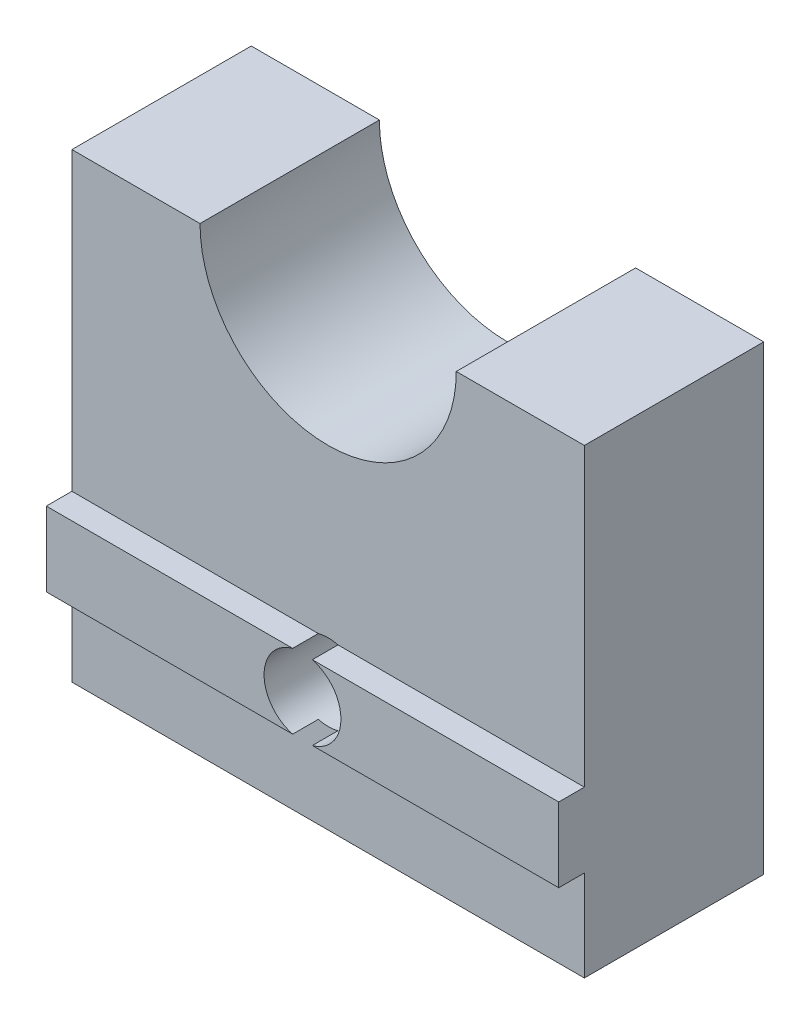
from build123d import *

# Parameters (mm, degrees)
BOSS_EXTRUDE1_DEPTH = 7
SKETCH2_W           = 1
SKETCH2_H           = 2.9
BOSS_EXTRUDE2_DEPTH = 20
SKETCH3_R           = 1.5
CUT_EXTRUDE1_DEPTH  = 9


with BuildPart() as part:
    # Sketch1 → Boss-Extrude1 (new body)
    with BuildSketch(Plane.XY):
        with BuildLine():
            Line((-10, 0), (10, 0))
            Line((10, 0), (10, 18))
            Line((10, 18), (5, 18))
            ThreePointArc((5, 18), (0, 13), (-5, 18))
            Line((-5, 18), (-10, 18))
            Line((-10, 18), (-10, 0))
        make_face()
    extrude(amount=BOSS_EXTRUDE1_DEPTH)

    # Sketch2 → Boss-Extrude2 (add)
    with BuildSketch(Plane.ZY.offset(10)):
        with Locations((7.5, 5)):
            Rectangle(SKETCH2_W, SKETCH2_H)
    extrude(amount=-BOSS_EXTRUDE2_DEPTH)

    # Sketch3 → Cut-Extrude1 (cut, through all)
    with BuildSketch(Plane.XY.offset(8)):
        with Locations((0, 5)):
            Circle(SKETCH3_R)
    extrude(amount=-CUT_EXTRUDE1_DEPTH, mode=Mode.SUBTRACT)


solid = part.part
